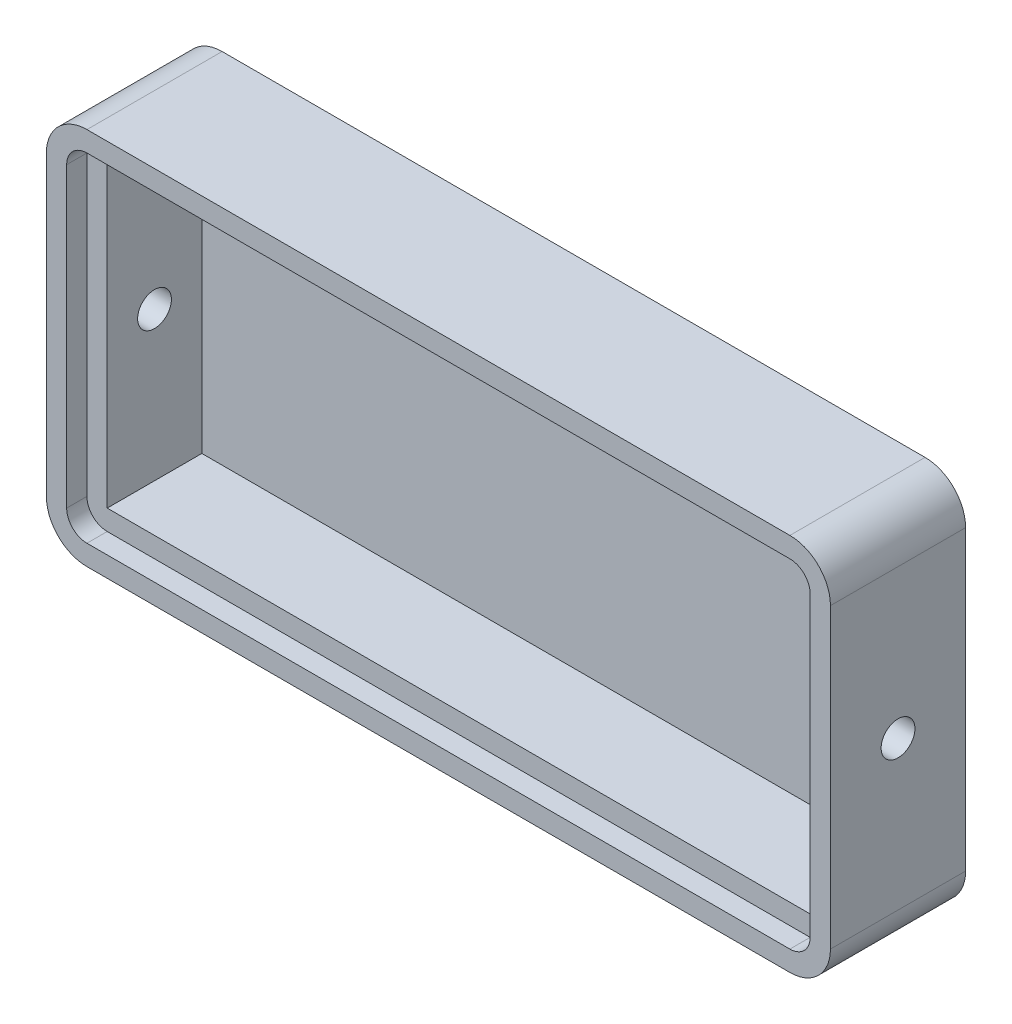
from build123d import *

# Parameters (mm, degrees)
ESQUISSE1_W             = 116
ESQUISSE1_H             = 56
BOSS_EXTRU_1_DEPTH      = 20
CONG_1_R                = 6
COQUE1_T                = -3
ESQUISSE2_W             = 104
ESQUISSE2_H             = 44
BOSS_EXTRU_2_DEPTH      = 14
ESQUISSE3_R             = 2.5
ENL_V_MAT_EXTRU_1_DEPTH = 121.995867698


with BuildPart() as part:
    # Esquisse1 → Boss.-Extru.1 (new body)
    with BuildSketch(Plane.XY):
        Rectangle(ESQUISSE1_W, ESQUISSE1_H)
    extrude(amount=BOSS_EXTRU_1_DEPTH)

    # Congé1
    cong_1_edges = [part.edges().sort_by_distance(p)[0] for p in [
        (58, -28, 10),
        (-58, -28, 10),
        (-58, 28, 10),
        (58, 28, 10),
    ]]
    fillet(cong_1_edges, radius=CONG_1_R)

    # Coque1
    coque1_openings = [part.faces().sort_by_distance(p)[0] for p in [
        (0, 0, 20),
    ]]
    offset(amount=COQUE1_T, openings=coque1_openings, kind=Kind.INTERSECTION)

    # Esquisse2 → Boss.-Extru.2 (add)
    with BuildSketch(Plane.XY.offset(3)):
        with BuildLine():
            Line((52, 25), (-52, 25))
            ThreePointArc((-52, 25), (-54.121320344, 24.121320344), (-55, 22))
            Line((-55, 22), (-55, -22))
            ThreePointArc((-55, -22), (-54.121320344, -24.121320344), (-52, -25))
            Line((-52, -25), (52, -25))
            ThreePointArc((52, -25), (54.121320344, -24.121320344), (55, -22))
            Line((55, -22), (55, 22))
            ThreePointArc((55, 22), (54.121320344, 24.121320344), (52, 25))
        make_face()
        Rectangle(ESQUISSE2_W, ESQUISSE2_H, mode=Mode.SUBTRACT)
    extrude(amount=BOSS_EXTRU_2_DEPTH)

    # Esquisse3 → Enlèv. mat.-Extru.1 (cut, through all)
    with BuildSketch(Plane.ZY.offset(58)):
        with Locations((10, 0)):
            Circle(ESQUISSE3_R)
    extrude(amount=-ENL_V_MAT_EXTRU_1_DEPTH, mode=Mode.SUBTRACT)


solid = part.part
